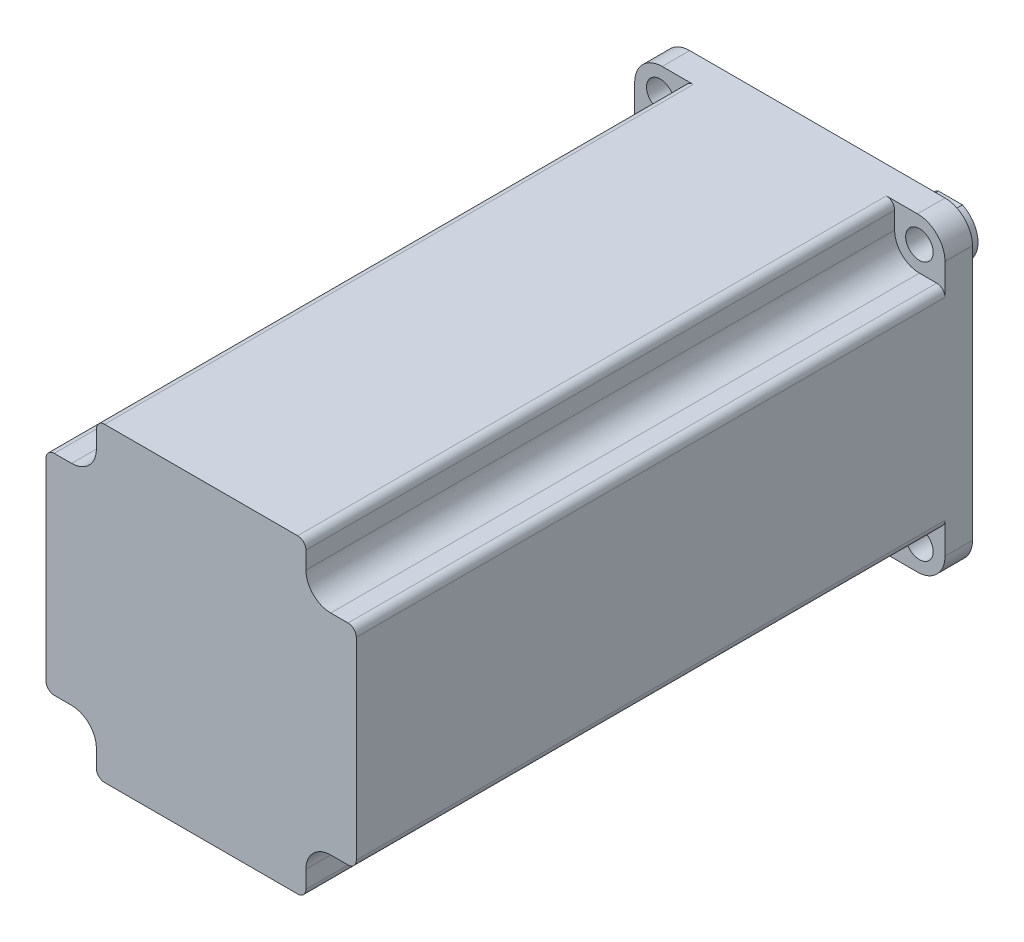
from build123d import *

# Parameters (mm, degrees)
SKETCH1_W           = 56.4
SKETCH1_H           = 56.4
SKETCH1_R           = 2.5
BOSS_EXTRUDE1_DEPTH = 112
SKETCH1_3_R         = 19.05
BOSS_EXTRUDE2_DEPTH = 1.6
FILLET1_R           = 5
CUT_EXTRUDE1_DEPTH  = 107
FILLET2_R           = 1.5
SKETCH1_4_R         = 5
BOSS_EXTRUDE3_DEPTH = 24.2
SKETCH3_W           = 4.358898944
SKETCH3_H           = 0.854235542
CUT_EXTRUDE2_DEPTH  = 20


with BuildPart() as part:
    # Sketch1 → Boss-Extrude1 (new body)
    with BuildSketch(Plane.XY):
        Rectangle(SKETCH1_W, SKETCH1_H)
        with Locations((-23.55, -23.55)):
            Circle(SKETCH1_R, mode=Mode.SUBTRACT)
        with Locations((23.55, -23.55)):
            Circle(SKETCH1_R, mode=Mode.SUBTRACT)
        with Locations((-23.55, 23.55)):
            Circle(SKETCH1_R, mode=Mode.SUBTRACT)
        with Locations((23.55, 23.55)):
            Circle(SKETCH1_R, mode=Mode.SUBTRACT)
    extrude(amount=BOSS_EXTRUDE1_DEPTH)

    # Sketch1_3 → Boss-Extrude2 (add)
    with BuildSketch(Plane.XY):
        Circle(SKETCH1_3_R)
    extrude(amount=-BOSS_EXTRUDE2_DEPTH)

    # Fillet1
    fillet1_edges = [part.edges().sort_by_distance(p)[0] for p in [
        (-28.2, 28.2, 56),
        (-28.2, -28.2, 56),
        (28.2, -28.2, 56),
        (28.2, 28.2, 56),
    ]]
    fillet(fillet1_edges, radius=FILLET1_R)

    # Sketch2 → Cut-Extrude1 (cut)
    with BuildSketch(Plane.XY.offset(112)):
        with BuildLine():
            Line((-23.55, 19.044974747), (-31.616752069, 19.044974747))
            Line((-31.616752069, 19.044974747), (-31.616752069, 32.365774456))
            Line((-31.616752069, 32.365774456), (-19.044974747, 32.365774456))
            Line((-19.044974747, 32.365774456), (-19.044974747, 23.55))
            ThreePointArc((-19.044974747, 23.55), (-20.364466094, 20.364466094), (-23.55, 19.044974747))
        make_face()
        with BuildLine():
            Line((19.044974747, 23.55), (19.044974747, 31.616752069))
            Line((19.044974747, 31.616752069), (32.365774456, 31.616752069))
            Line((32.365774456, 31.616752069), (32.365774456, 19.044974747))
            Line((32.365774456, 19.044974747), (23.55, 19.044974747))
            ThreePointArc((23.55, 19.044974747), (20.364466094, 20.364466094), (19.044974747, 23.55))
        make_face()
        with BuildLine():
            Line((23.55, -19.044974747), (31.616752069, -19.044974747))
            Line((31.616752069, -19.044974747), (31.616752069, -32.365774456))
            Line((31.616752069, -32.365774456), (19.044974747, -32.365774456))
            Line((19.044974747, -32.365774456), (19.044974747, -23.55))
            ThreePointArc((19.044974747, -23.55), (20.364466094, -20.364466094), (23.55, -19.044974747))
        make_face()
        with BuildLine():
            Line((-19.044974747, -23.55), (-19.044974747, -31.616752069))
            Line((-19.044974747, -31.616752069), (-32.365774456, -31.616752069))
            Line((-32.365774456, -31.616752069), (-32.365774456, -19.044974747))
            Line((-32.365774456, -19.044974747), (-23.55, -19.044974747))
            ThreePointArc((-23.55, -19.044974747), (-20.364466094, -20.364466094), (-19.044974747, -23.55))
        make_face()
    extrude(amount=-CUT_EXTRUDE1_DEPTH, mode=Mode.SUBTRACT)

    # Fillet2
    fillet2_edges = [part.edges().sort_by_distance(p)[0] for p in [
        (-28.2, -19.044974747, 58.5),
        (-19.044974747, -28.2, 58.5),
        (19.044974747, -28.2, 58.5),
        (28.2, -19.044974747, 58.5),
        (28.2, 19.044974747, 58.5),
        (19.044974747, 28.2, 58.5),
        (-19.044974747, 28.2, 58.5),
        (-28.2, 19.044974747, 58.5),
    ]]
    fillet(fillet2_edges, radius=FILLET2_R)

    # Sketch1_4 → Boss-Extrude3 (add)
    with BuildSketch(Plane.XY):
        Circle(SKETCH1_4_R)
    extrude(amount=-BOSS_EXTRUDE3_DEPTH)

    # Sketch3 → Cut-Extrude2 (cut)
    with BuildSketch(Plane(origin=(0, 0, -24.2), x_dir=(-1, 0, 0), z_dir=(0, 0, -1))):
        with Locations((0, 4.927117771)):
            Rectangle(SKETCH3_W, SKETCH3_H)
    extrude(amount=-CUT_EXTRUDE2_DEPTH, mode=Mode.SUBTRACT)


solid = part.part
